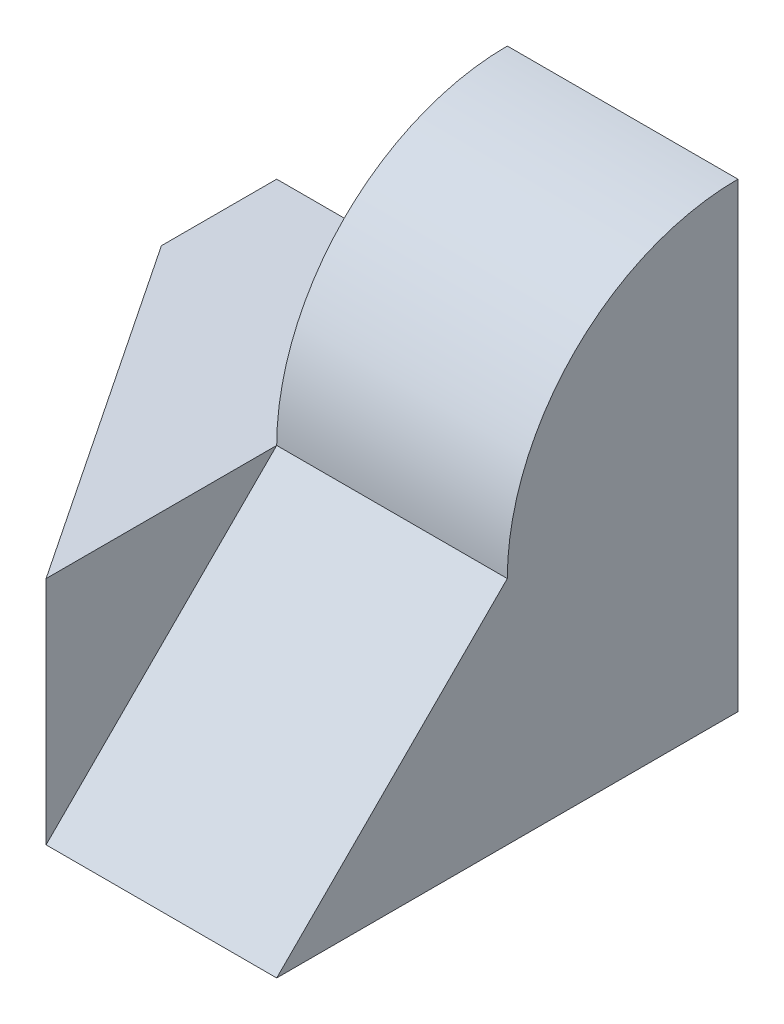
from build123d import *

# Parameters (mm, degrees)
BOSS_EXTRUDE1_DEPTH = 40
CUT_EXTRUDE1_DEPTH  = 40
CUT_EXTRUDE2_DEPTH  = 40
CUT_EXTRUDE4_DEPTH  = 20


with BuildPart() as part:
    # Sketch1 → Boss-Extrude1 (new body)
    with BuildSketch(Plane.XY):
        Polygon((0, 0), (0, 40), (-20, 40), (-20, 20), (-40, 20), (-40, 0), align=None)
    extrude(amount=BOSS_EXTRUDE1_DEPTH)

    # Sketch3 → Cut-Extrude1 (cut)
    with BuildSketch(Plane.ZY.offset(20)):
        with BuildLine():
            Line((40, 40), (0, 40))
            ThreePointArc((0, 40), (14.142135624, 34.142135624), (20, 20))
            Line((20, 20), (40, 20))
            Line((40, 20), (40, 40))
        make_face()
    extrude(amount=-CUT_EXTRUDE1_DEPTH, mode=Mode.SUBTRACT)

    # Sketch5 → Cut-Extrude2 (cut)
    with BuildSketch(Plane(origin=(0, 20, 0), x_dir=(1, 0, 0), z_dir=(0, 1, 0))):
        Polygon((-20, -40), (-40, -10), (-40, -40), align=None)
    extrude(amount=-CUT_EXTRUDE2_DEPTH, mode=Mode.SUBTRACT)

    # Sketch8 → Cut-Extrude4 (cut)
    with BuildSketch(Plane(origin=(0, 0, 0), x_dir=(0, 0, -1), z_dir=(1, 0, 0))):
        Polygon((-20, 20), (-40, 0), (-40, 20), align=None)
    extrude(amount=-CUT_EXTRUDE4_DEPTH, mode=Mode.SUBTRACT)


solid = part.part
